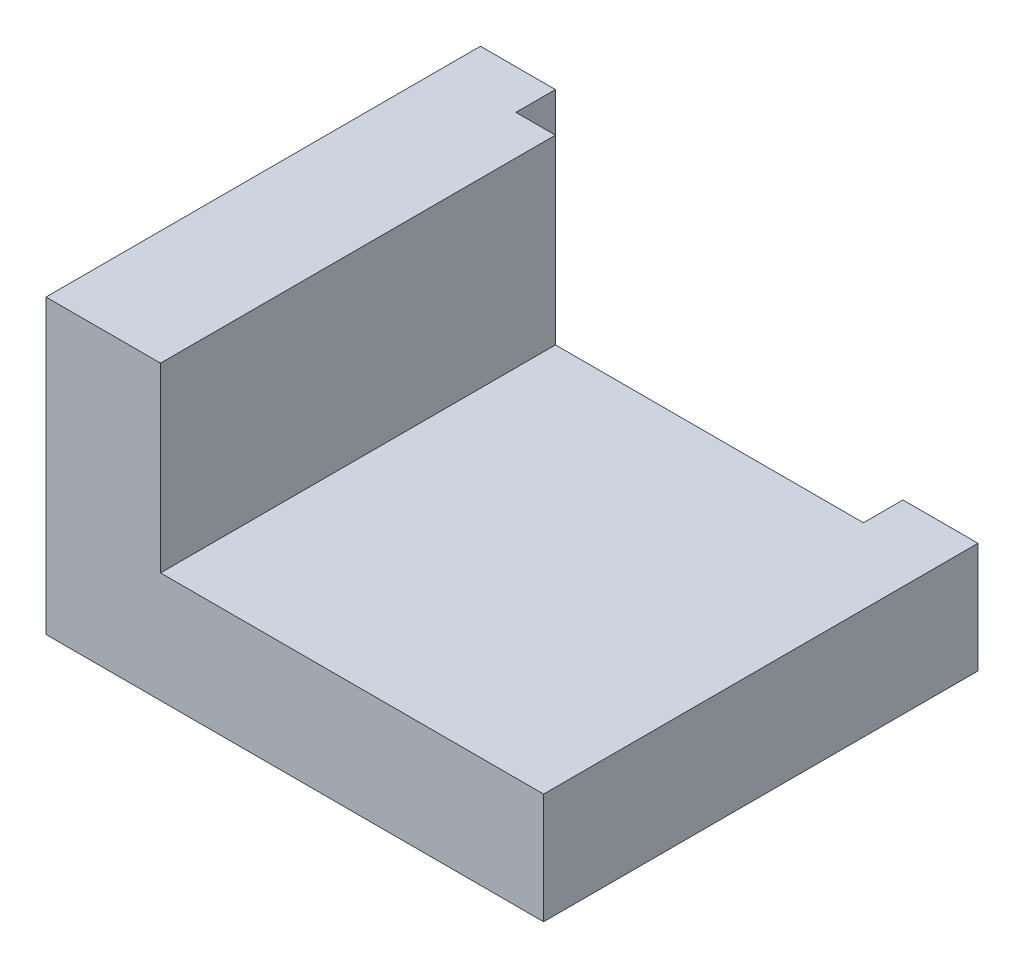
from build123d import *

# Parameters (mm, degrees)
BOSS_EXTRUDE1_DEPTH = 5
BOSS_EXTRUDE3_DEPTH = 50


with BuildPart() as part:
    # Sketch1 → Boss-Extrude1 (new body)
    with BuildSketch(Plane.XY):
        Polygon((0, 0), (0, 37), (9.5, 37), (9.5, 4), (53.5, 4), (53.5, 14), (63, 14), (63, 0), align=None)
    extrude(amount=BOSS_EXTRUDE1_DEPTH)

    # Sketch2 → Boss-Extrude3 (add)
    with BuildSketch(Plane.XY.offset(5)):
        Polygon((0, 37), (14.5, 37), (14.5, 14), (63, 14), (63, 0), (0, 0), align=None)
    extrude(amount=BOSS_EXTRUDE3_DEPTH)


solid = part.part
